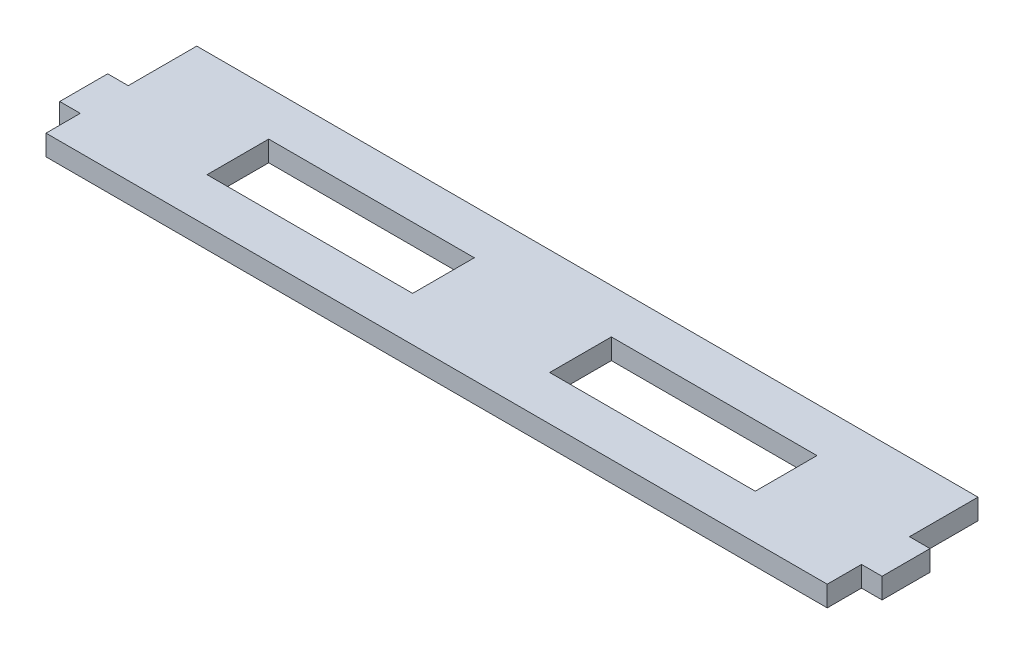
from build123d import *

# Parameters (mm, degrees)
SALIENTE_EXTRUIR1_DEPTH = 3
CROQUIS2_W              = 30
CROQUIS2_H              = 9
CORTAR_EXTRUIR1_DEPTH   = 4


with BuildPart() as part:
    # Croquis1 → Saliente-Extruir1 (new body)
    with BuildSketch(Plane(origin=(0, 0, 0), x_dir=(1, 0, 0), z_dir=(0, 1, 0))):
        Polygon((-57, 1), (-60, 1), (-60, -6), (-57, -6), (-57, -11), (57, -11), (57, -6), (60, -6), (60, 1), (57, 1), (57, 11), (-57, 11), align=None)
    extrude(amount=SALIENTE_EXTRUIR1_DEPTH)

    # Croquis2 → Cortar-Extruir1 (cut, through all)
    with BuildSketch(Plane(origin=(0, 3, 0), x_dir=(1, 0, 0), z_dir=(0, 1, 0))):
        with Locations((-25, 0)):
            Rectangle(CROQUIS2_W, CROQUIS2_H)
        with Locations((25, 0)):
            Rectangle(CROQUIS2_W, CROQUIS2_H)
    extrude(amount=-CORTAR_EXTRUIR1_DEPTH, mode=Mode.SUBTRACT)


solid = part.part
